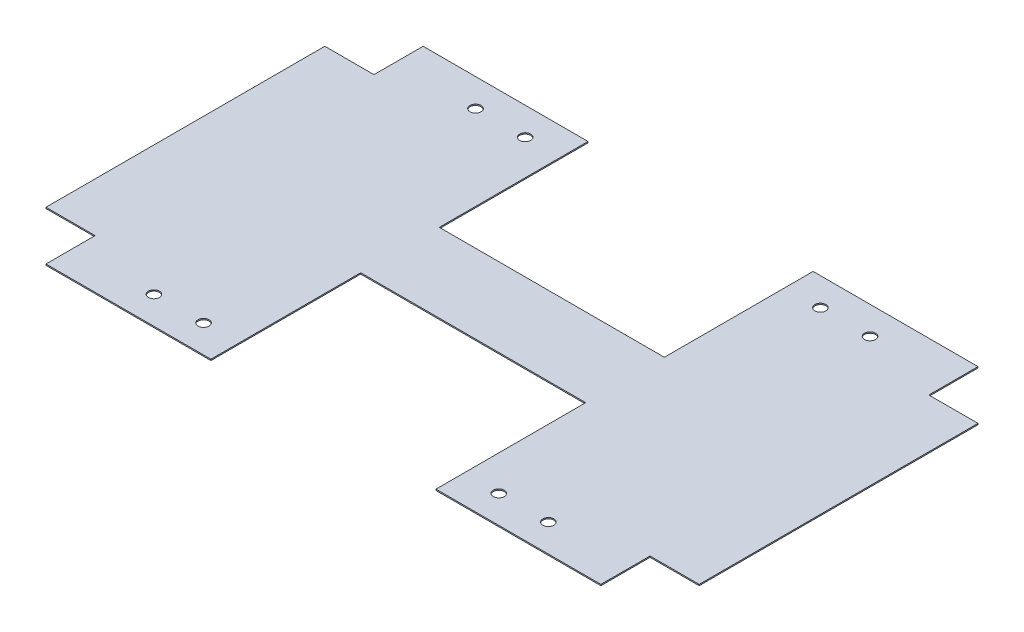
from build123d import *

# Parameters (mm, degrees)
SKETCH1_R           = 1.125
BOSS_EXTRUDE1_DEPTH = 0.25


with BuildPart() as part:
    # Sketch1 → Boss-Extrude1 (new body)
    with BuildSketch(Plane(origin=(0, 0, 0), x_dir=(1, 0, 0), z_dir=(0, 1, 0))):
        Polygon((-22.9, 38.37), (-22.9, 8.105), (22.9, 8.105), (22.9, 38.37), (56.46, 38.37), (56.46, 28.37), (66.46, 28.37), (66.46, -28.37), (56.46, -28.37), (56.46, -38.37), (22.9, -38.37), (22.9, -7.895), (-22.9, -7.895), (-22.9, -38.37), (-56.46, -38.37), (-56.46, -28.37), (-66.46, -28.37), (-66.46, 28.37), (-56.46, 28.37), (-56.46, 38.37), align=None)
        with Locations(Location((-40.14, 32.72, 0), (0, 0, 270))):  # turned: the seam where the file's is
            Circle(SKETCH1_R, mode=Mode.SUBTRACT)
        with Locations(Location((-30.04, 32.72, 0), (0, 0, 270))):  # turned: the seam where the file's is
            Circle(SKETCH1_R, mode=Mode.SUBTRACT)
        with Locations(Location((30.04, 32.72, 0), (0, 0, 270))):  # turned: the seam where the file's is
            Circle(SKETCH1_R, mode=Mode.SUBTRACT)
        with Locations(Location((40.14, 32.72, 0), (0, 0, 270))):  # turned: the seam where the file's is
            Circle(SKETCH1_R, mode=Mode.SUBTRACT)
        with Locations(Location((40.14, -32.73, 0), (0, 0, 270))):  # turned: the seam where the file's is
            Circle(SKETCH1_R, mode=Mode.SUBTRACT)
        with Locations(Location((30.04, -32.73, 0), (0, 0, 270))):  # turned: the seam where the file's is
            Circle(SKETCH1_R, mode=Mode.SUBTRACT)
        with Locations(Location((-30.04, -32.73, 0), (0, 0, 270))):  # turned: the seam where the file's is
            Circle(SKETCH1_R, mode=Mode.SUBTRACT)
        with Locations(Location((-40.14, -32.73, 0), (0, 0, 270))):  # turned: the seam where the file's is
            Circle(SKETCH1_R, mode=Mode.SUBTRACT)
    extrude(amount=BOSS_EXTRUDE1_DEPTH)


solid = part.part
